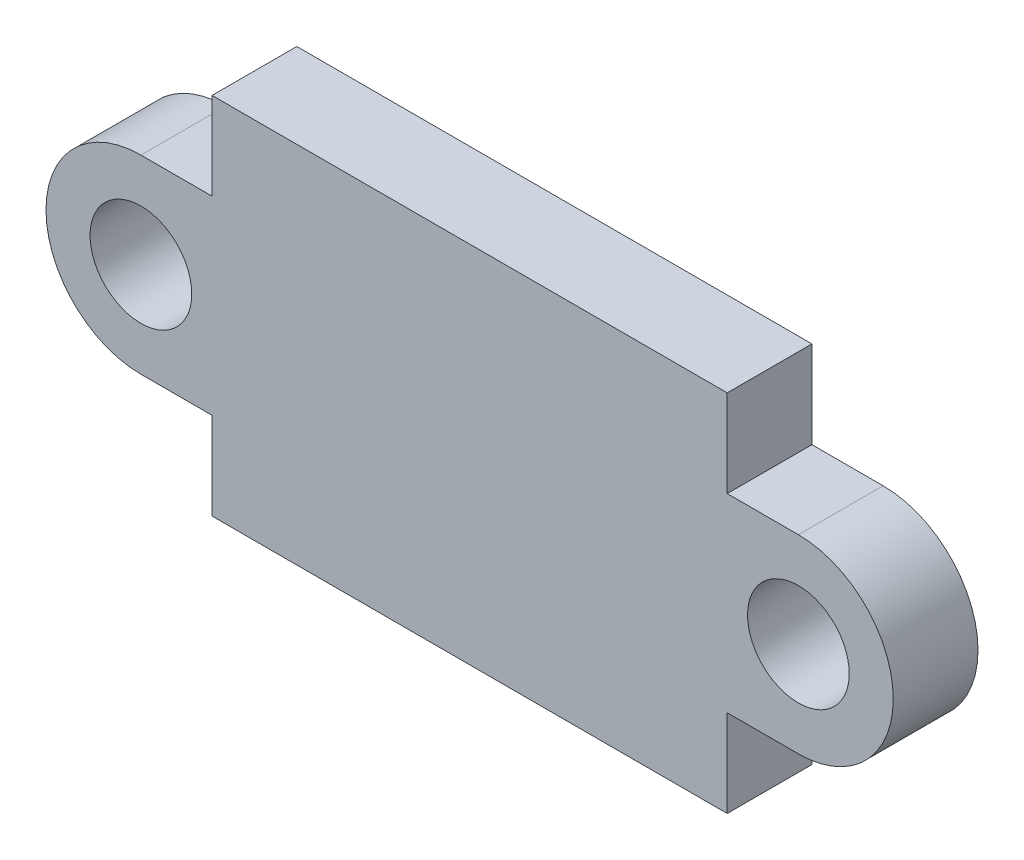
from build123d import *

# Parameters (mm, degrees)
BOSS_EXTRUDE1_DEPTH = 2.5
SKETCH2_R           = 1.5
CUT_EXTRUDE1_DEPTH  = 2.5


with BuildPart() as part:
    # Sketch1 → Boss-Extrude1 (new body)
    with BuildSketch(Plane.XY):
        with BuildLine():
            Line((7.6, -2.8), (7.6, -5.375))
            Line((7.6, -5.375), (-7.6, -5.375))
            Line((-7.6, -5.375), (-7.6, -2.8))
            Line((-7.6, -2.8), (-9.7, -2.8))
            ThreePointArc((-9.7, -2.8), (-12.5, 0), (-9.7, 2.8))
            Line((-9.7, 2.8), (-7.6, 2.8))
            Line((-7.6, 2.8), (-7.6, 5.375))
            Line((-7.6, 5.375), (7.6, 5.375))
            Line((7.6, 5.375), (7.6, 2.8))
            Line((7.6, 2.8), (9.7, 2.8))
            ThreePointArc((9.7, 2.8), (12.5, 0), (9.7, -2.8))
            Line((9.7, -2.8), (7.6, -2.8))
        make_face()
    extrude(amount=BOSS_EXTRUDE1_DEPTH)

    # Sketch2 → Cut-Extrude1 (cut)
    with BuildSketch(Plane.XY.offset(2.5)):
        with Locations((-9.7, 0)):
            Circle(SKETCH2_R)
        with Locations((9.7, 0)):
            Circle(SKETCH2_R)
    extrude(amount=-CUT_EXTRUDE1_DEPTH, mode=Mode.SUBTRACT)


solid = part.part
